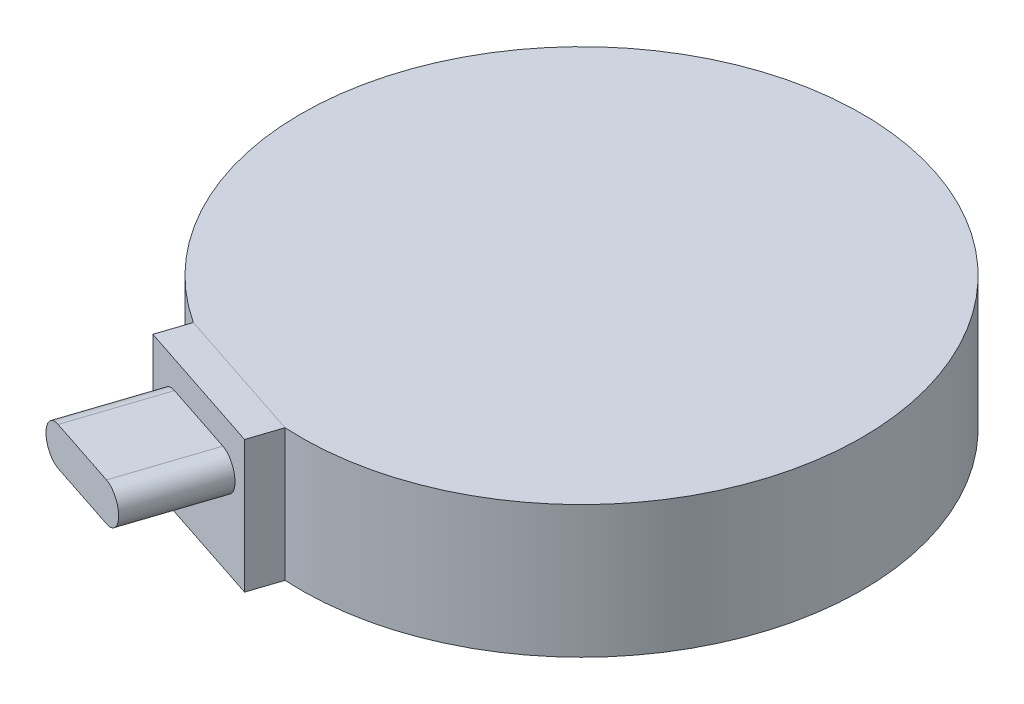
from build123d import *

# Parameters (mm, degrees)
SKETCH1_R           = 70
BOSS_EXTRUDE1_DEPTH = 33
SKETCH4_W           = 36
SKETCH4_H           = 33.003390547
BOSS_EXTRUDE2_DEPTH = 8
BOSS_EXTRUDE3_DEPTH = 23
SKETCH10_R          = 13.35
CUT_EXTRUDE1_DEPTH  = 14
CHAMFER2_SIZE       = 6


with BuildPart() as part:
    # Sketch1 → Boss-Extrude1 (new body)
    with BuildSketch(Plane(origin=(0, 0, 0), x_dir=(1, 0, 0), z_dir=(0, 1, 0))):
        Circle(SKETCH1_R)
    extrude(amount=BOSS_EXTRUDE1_DEPTH)

    # Sketch4 → Boss-Extrude2 (add)
    with BuildSketch(Plane(origin=(-21.221579415, 0, 64.231180646), x_dir=(0.949517333, 0, 0.313714574), z_dir=(-0.313714574, 0, 0.949517333))):
        with Locations((0, 16.501695274)):
            Rectangle(SKETCH4_W, SKETCH4_H)
    extrude(amount=BOSS_EXTRUDE2_DEPTH)

    # Sketch7 → Boss-Extrude3 (add)
    with BuildSketch(Plane(origin=(-23.731296009, 0, 71.827319311), x_dir=(0.949517333, 0, 0.313714574), z_dir=(-0.313714574, 0, 0.949517333))):
        with BuildLine():
            Line((-9.5, 26.2), (9.5, 26.2))
            ThreePointArc((9.5, 26.2), (14.25, 21.45), (9.5, 16.7))
            Line((9.5, 16.7), (-9.5, 16.7))
            ThreePointArc((-9.5, 16.7), (-14.25, 21.45), (-9.5, 26.2))
        make_face()
    extrude(amount=BOSS_EXTRUDE3_DEPTH)

    # Sketch10 → Cut-Extrude1 (cut)
    with BuildSketch(Plane.XZ):
        Circle(SKETCH10_R)
    extrude(amount=-CUT_EXTRUDE1_DEPTH, mode=Mode.SUBTRACT)

    # Chamfer2
    chamfer2_edges = [part.edges().sort_by_distance(p)[0] for p in [
        (-13.35, 0, 0),
    ]]
    chamfer(chamfer2_edges, length=CHAMFER2_SIZE)


solid = part.part
